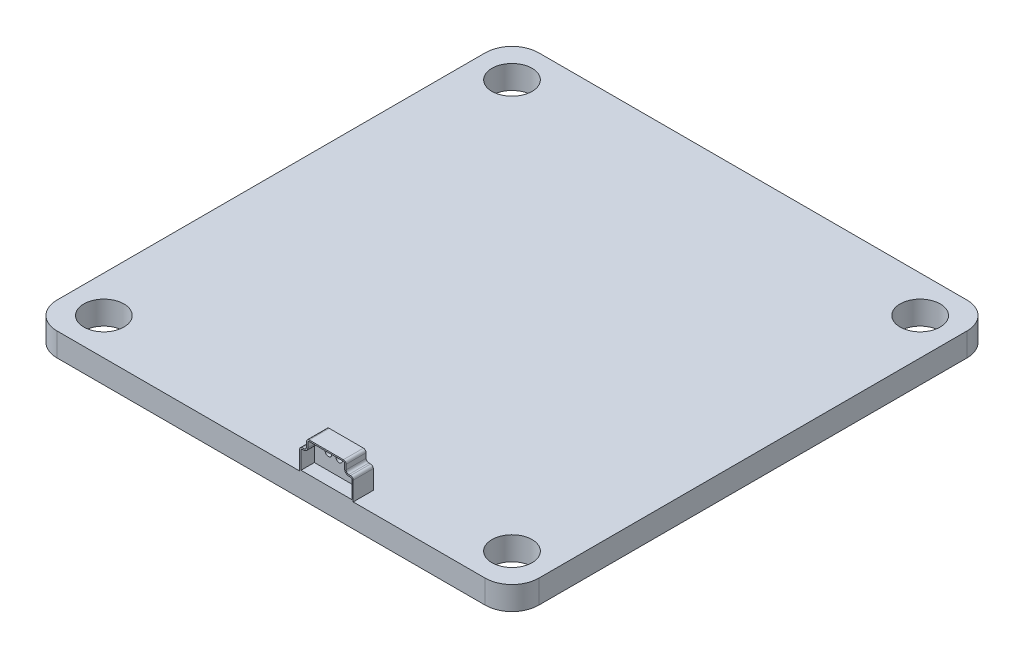
from build123d import *

# Parameters (mm, degrees)
SKETCH1_R           = 1.5
BOSS_EXTRUDE1_DEPTH = 1.75
BOSS_EXTRUDE6_DEPTH = 1
BOSS_EXTRUDE7_DEPTH = 0.5
CUT_EXTRUDE1_REACH  = 3.5
SKETCH7_R           = 0.25


with BuildPart() as part:
    # Sketch1 → Boss-Extrude1 (new body)
    with BuildSketch(Plane(origin=(0, 0, 0), x_dir=(1, 0, 0), z_dir=(0, 1, 0))):
        with BuildLine():
            Line((-16, 18), (16, 18))
            ThreePointArc((16, 18), (17.414213562, 17.414213562), (18, 16))
            Line((18, 16), (18, -16))
            ThreePointArc((18, -16), (17.414213562, -17.414213562), (16, -18))
            Line((16, -18), (-16, -18))
            ThreePointArc((-16, -18), (-17.414213562, -17.414213562), (-18, -16))
            Line((-18, -16), (-18, 16))
            ThreePointArc((-18, 16), (-17.414213562, 17.414213562), (-16, 18))
        make_face()
        with Locations((-15.25, 15.25)):
            Circle(SKETCH1_R, mode=Mode.SUBTRACT)
        with Locations((15.25, 15.25)):
            Circle(SKETCH1_R, mode=Mode.SUBTRACT)
        with Locations((-15.25, -15.25)):
            Circle(SKETCH1_R, mode=Mode.SUBTRACT)
        with Locations((15.25, -15.25)):
            Circle(SKETCH1_R, mode=Mode.SUBTRACT)
    extrude(amount=BOSS_EXTRUDE1_DEPTH)

    # Sketch2 → Boss-Extrude6 (add)
    with BuildSketch(Plane.XY.offset(18)):
        with BuildLine():
            Line((2.843456523, 4.116656207), (5.398697456, 4.116656207))
            ThreePointArc((5.398697456, 4.116656207), (5.540118812, 4.058077564), (5.598697456, 3.916656207))
            Line((5.598697456, 3.916656207), (5.598697456, 3.555649959))
            ThreePointArc((5.598697456, 3.555649959), (5.6572761, 3.414228602), (5.798697456, 3.355649959))
            Line((5.798697456, 3.355649959), (5.933688948, 3.355649959))
            ThreePointArc((5.933688948, 3.355649959), (6.075110304, 3.297071315), (6.133688948, 3.155649959))
            Line((6.133688948, 3.155649959), (6.133688948, 1.75))
            Line((6.133688948, 1.75), (2.133688948, 1.75))
            Line((2.133688948, 1.75), (2.133688948, 3.155649959))
            ThreePointArc((2.133688948, 3.155649959), (2.192267592, 3.297071315), (2.333688948, 3.355649959))
            Line((2.333688948, 3.355649959), (2.443456523, 3.355649959))
            ThreePointArc((2.443456523, 3.355649959), (2.58487788, 3.414228602), (2.643456523, 3.555649959))
            Line((2.643456523, 3.555649959), (2.643456523, 3.916656207))
            ThreePointArc((2.643456523, 3.916656207), (2.702035167, 4.058077564), (2.843456523, 4.116656207))
        make_face()
        with BuildLine():
            Line((2.843456523, 4.016656207), (5.398697456, 4.016656207))
            ThreePointArc((5.398697456, 4.016656207), (5.469408134, 3.987366886), (5.498697456, 3.916656207))
            Line((5.498697456, 3.916656207), (5.498697456, 3.555649959))
            ThreePointArc((5.498697456, 3.555649959), (5.586565422, 3.343517924), (5.798697456, 3.255649959))
            Line((5.798697456, 3.255649959), (5.933688948, 3.255649959))
            ThreePointArc((5.933688948, 3.255649959), (6.004399626, 3.226360637), (6.033688948, 3.155649959))
            Line((6.033688948, 3.155649959), (6.033688948, 1.85))
            Line((6.033688948, 1.85), (2.233688948, 1.85))
            Line((2.233688948, 1.85), (2.233688948, 3.155649959))
            ThreePointArc((2.233688948, 3.155649959), (2.26297827, 3.226360637), (2.333688948, 3.255649959))
            Line((2.333688948, 3.255649959), (2.443456523, 3.255649959))
            ThreePointArc((2.443456523, 3.255649959), (2.655588558, 3.343517924), (2.743456523, 3.555649959))
            Line((2.743456523, 3.555649959), (2.743456523, 3.916656207))
            ThreePointArc((2.743456523, 3.916656207), (2.772745845, 3.987366886), (2.843456523, 4.016656207))
        make_face(mode=Mode.SUBTRACT)
    extrude(amount=-BOSS_EXTRUDE6_DEPTH)

    # Sketch6 → Boss-Extrude7 (add)
    with BuildSketch(Plane(origin=(0, 0, 17), x_dir=(-1, 0, 0), z_dir=(0, 0, -1))):
        with BuildLine():
            Line((-5.598697456, 3.916656207), (-5.598697456, 3.555649959))
            ThreePointArc((-5.598697456, 3.555649959), (-5.6572761, 3.414228602), (-5.798697456, 3.355649959))
            Line((-5.798697456, 3.355649959), (-5.933688948, 3.355649959))
            ThreePointArc((-5.933688948, 3.355649959), (-6.075110304, 3.297071315), (-6.133688948, 3.155649959))
            Line((-6.133688948, 3.155649959), (-6.133688948, 1.75))
            Line((-6.133688948, 1.75), (-2.133688948, 1.75))
            Line((-2.133688948, 1.75), (-2.133688948, 3.155649959))
            ThreePointArc((-2.133688948, 3.155649959), (-2.192267592, 3.297071315), (-2.333688948, 3.355649959))
            Line((-2.333688948, 3.355649959), (-2.443456523, 3.355649959))
            ThreePointArc((-2.443456523, 3.355649959), (-2.58487788, 3.414228602), (-2.643456523, 3.555649959))
            Line((-2.643456523, 3.555649959), (-2.643456523, 3.916656207))
            ThreePointArc((-2.643456523, 3.916656207), (-2.702035167, 4.058077564), (-2.843456523, 4.116656207))
            Line((-2.843456523, 4.116656207), (-5.398697456, 4.116656207))
            ThreePointArc((-5.398697456, 4.116656207), (-5.540118812, 4.058077564), (-5.598697456, 3.916656207))
        make_face()
    extrude(amount=BOSS_EXTRUDE7_DEPTH)

    # Sketch7 → Cut-Extrude1 (cut, up to next)
    with BuildSketch(Plane(origin=(0, 0, 16.5), x_dir=(-1, 0, 0), z_dir=(0, 0, -1)), mode=Mode.PRIVATE) as cut_extrude1_sk1:
        with Locations((-4.878111957, 3.016893087)):
            Circle(SKETCH7_R)
    cut_extrude1_tool1 = extrude(cut_extrude1_sk1.sketch, amount=-CUT_EXTRUDE1_REACH, mode=Mode.PRIVATE) & part.part
    add(cut_extrude1_tool1.solids().sort_by_distance((4.878112, 3.016893, 16.5))[0], mode=Mode.SUBTRACT)
    # Sketch7 → Cut-Extrude1 (cut, up to next)
    with BuildSketch(Plane(origin=(0, 0, 16.5), x_dir=(-1, 0, 0), z_dir=(0, 0, -1)), mode=Mode.PRIVATE) as cut_extrude1_sk2:
        with Locations((-4.078118838, 3.013574967)):
            Circle(SKETCH7_R)
    cut_extrude1_tool2 = extrude(cut_extrude1_sk2.sketch, amount=-CUT_EXTRUDE1_REACH, mode=Mode.PRIVATE) & part.part
    add(cut_extrude1_tool2.solids().sort_by_distance((4.078119, 3.013575, 16.5))[0], mode=Mode.SUBTRACT)
    # Sketch7 → Cut-Extrude1 (cut, up to next)
    with BuildSketch(Plane(origin=(0, 0, 16.5), x_dir=(-1, 0, 0), z_dir=(0, 0, -1)), mode=Mode.PRIVATE) as cut_extrude1_sk3:
        with Locations((-3.278127018, 3.00995723)):
            Circle(SKETCH7_R)
    cut_extrude1_tool3 = extrude(cut_extrude1_sk3.sketch, amount=-CUT_EXTRUDE1_REACH, mode=Mode.PRIVATE) & part.part
    add(cut_extrude1_tool3.solids().sort_by_distance((3.278127, 3.009957, 16.5))[0], mode=Mode.SUBTRACT)


solid = part.part
